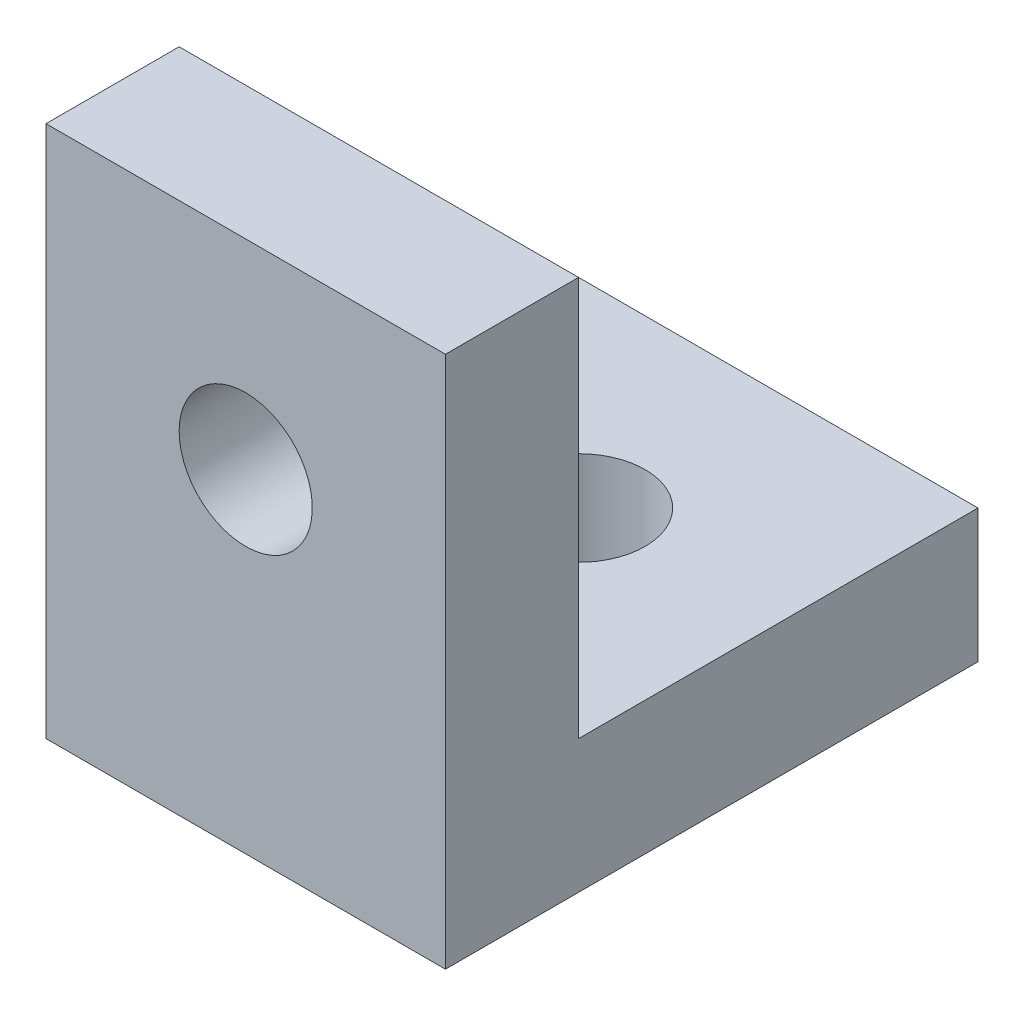
from build123d import *

# Parameters (mm, degrees)
BOSS_EXTRUDE1_DEPTH = 30
SKETCH2_R           = 5
CUT_EXTRUDE1_DEPTH  = 30
SKETCH3_R           = 5
CUT_EXTRUDE2_DEPTH  = 30


with BuildPart() as part:
    # Sketch1 → Boss-Extrude1 (new body)
    with BuildSketch(Plane(origin=(0, 0, 0), x_dir=(0, 0, -1), z_dir=(1, 0, 0))):
        Polygon((0, 0), (0, 40), (10, 40), (10, 10), (40, 10), (40, 0), align=None)
    extrude(amount=BOSS_EXTRUDE1_DEPTH)

    # Sketch2 → Cut-Extrude1 (cut)
    with BuildSketch(Plane(origin=(0, 0, -10), x_dir=(-1, 0, 0), z_dir=(0, 0, -1))):
        with Locations((-15, 25)):
            Circle(SKETCH2_R)
    extrude(amount=-CUT_EXTRUDE1_DEPTH, mode=Mode.SUBTRACT)

    # Sketch3 → Cut-Extrude2 (cut)
    with BuildSketch(Plane(origin=(0, 10, 0), x_dir=(1, 0, 0), z_dir=(0, 1, 0))):
        with Locations((15, 25)):
            Circle(SKETCH3_R)
    extrude(amount=-CUT_EXTRUDE2_DEPTH, mode=Mode.SUBTRACT)


solid = part.part
